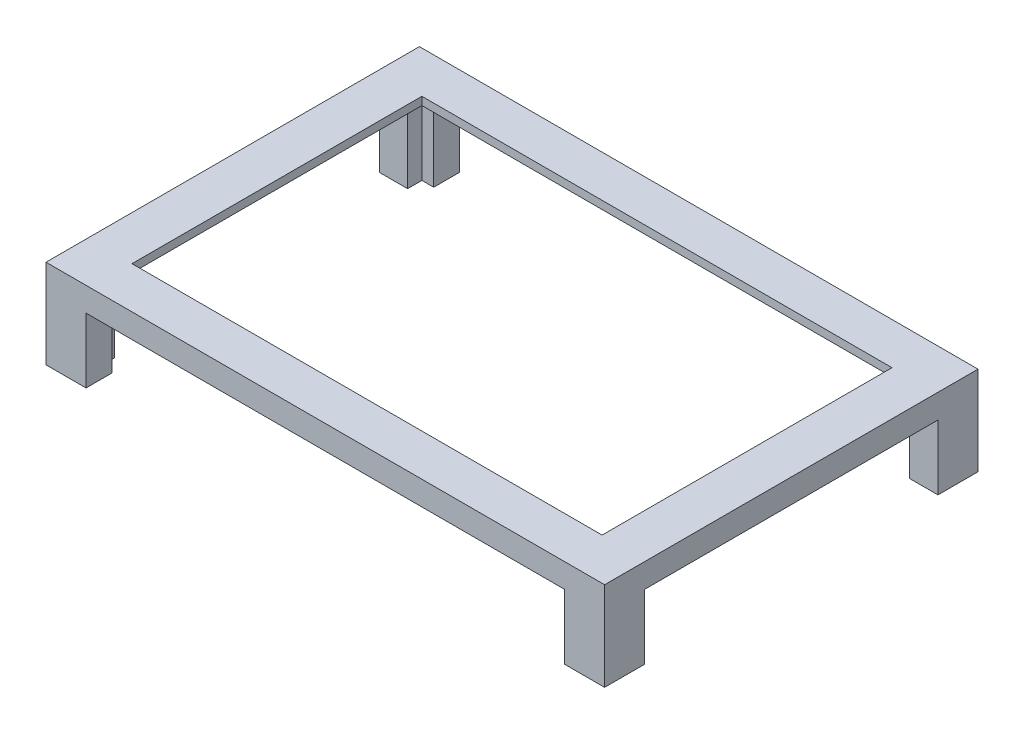
from build123d import *

# Parameters (mm, degrees)
SKETCH1_W           = 177.165
SKETCH1_H           = 118.4275
SKETCH1_W_2         = 159.258
SKETCH1_H_2         = 102.108
BOSS_EXTRUDE1_DEPTH = 28.194
SKETCH2_W           = 159.258
SKETCH2_H           = 2.54
BOSS_EXTRUDE2_DEPTH = 5.08
SKETCH3_W           = 97.028
SKETCH3_H           = 2.54
BOSS_EXTRUDE3_DEPTH = 5.08
SKETCH4_W           = 154.178
SKETCH4_H           = 2.54
BOSS_EXTRUDE4_DEPTH = 5.08
SKETCH5_W           = 91.948
SKETCH5_H           = 2.54
BOSS_EXTRUDE5_DEPTH = 5.08
SKETCH10_W          = 93.0275
SKETCH10_H          = 20.574
CUT_EXTRUDE4_DEPTH  = 198.628
SKETCH9_W           = 151.765
SKETCH9_H           = 20.574
CUT_EXTRUDE5_DEPTH  = 198.628
SKETCH11_R          = 1.37795
CUT_EXTRUDE6_DEPTH  = 12.7


with BuildPart() as part:
    # Sketch1 → Boss-Extrude1 (new body)
    with BuildSketch(Plane(origin=(0, 0, 0), x_dir=(1, 0, 0), z_dir=(0, 1, 0))):
        with Locations((79.375, -50.8)):
            Rectangle(SKETCH1_W, SKETCH1_H)
        with Locations((79.375, -50.8)):
            Rectangle(SKETCH1_W_2, SKETCH1_H_2, mode=Mode.SUBTRACT)
    extrude(amount=-BOSS_EXTRUDE1_DEPTH)

    # Sketch2 → Boss-Extrude2 (add)
    with BuildSketch(Plane.XY.offset(-0.254)):
        with Locations((79.375, -1.27)):
            Rectangle(SKETCH2_W, SKETCH2_H)
    extrude(amount=BOSS_EXTRUDE2_DEPTH)

    # Sketch3 → Boss-Extrude3 (add)
    with BuildSketch(Plane(origin=(-0.254, 0, 0), x_dir=(0, 0, -1), z_dir=(1, 0, 0))):
        with Locations((-53.34, -1.27)):
            Rectangle(SKETCH3_W, SKETCH3_H)
    extrude(amount=BOSS_EXTRUDE3_DEPTH)

    # Sketch4 → Boss-Extrude4 (add)
    with BuildSketch(Plane(origin=(0, 0, 101.854), x_dir=(-1, 0, 0), z_dir=(0, 0, -1))):
        with Locations((-81.915, -1.27)):
            Rectangle(SKETCH4_W, SKETCH4_H)
    extrude(amount=BOSS_EXTRUDE4_DEPTH)

    # Sketch5 → Boss-Extrude5 (add)
    with BuildSketch(Plane.ZY.offset(-159.004)):
        with Locations((50.8, -1.27)):
            Rectangle(SKETCH5_W, SKETCH5_H)
    extrude(amount=BOSS_EXTRUDE5_DEPTH)

    # Sketch10 → Cut-Extrude4 (cut)
    with BuildSketch(Plane.ZY.offset(9.2075)):
        with Locations((50.8, -17.907)):
            Rectangle(SKETCH10_W, SKETCH10_H)
    extrude(amount=-CUT_EXTRUDE4_DEPTH, mode=Mode.SUBTRACT)

    # Sketch9 → Cut-Extrude5 (cut)
    with BuildSketch(Plane.XY.offset(110.01375)):
        with Locations((79.375, -17.907)):
            Rectangle(SKETCH9_W, SKETCH9_H)
    extrude(amount=-CUT_EXTRUDE5_DEPTH, mode=Mode.SUBTRACT)

    # Sketch11 → Cut-Extrude6 (cut)
    with BuildSketch(Plane.XZ.offset(28.194)):
        with Locations((-4.8895, 106.58475)):
            Circle(SKETCH11_R)
        with Locations((-4.8895, -4.92125)):
            Circle(SKETCH11_R)
        with Locations((163.7665, -4.92125)):
            Circle(SKETCH11_R)
        with Locations((163.7665, 106.58475)):
            Circle(SKETCH11_R)
    extrude(amount=-CUT_EXTRUDE6_DEPTH, mode=Mode.SUBTRACT)


solid = part.part
